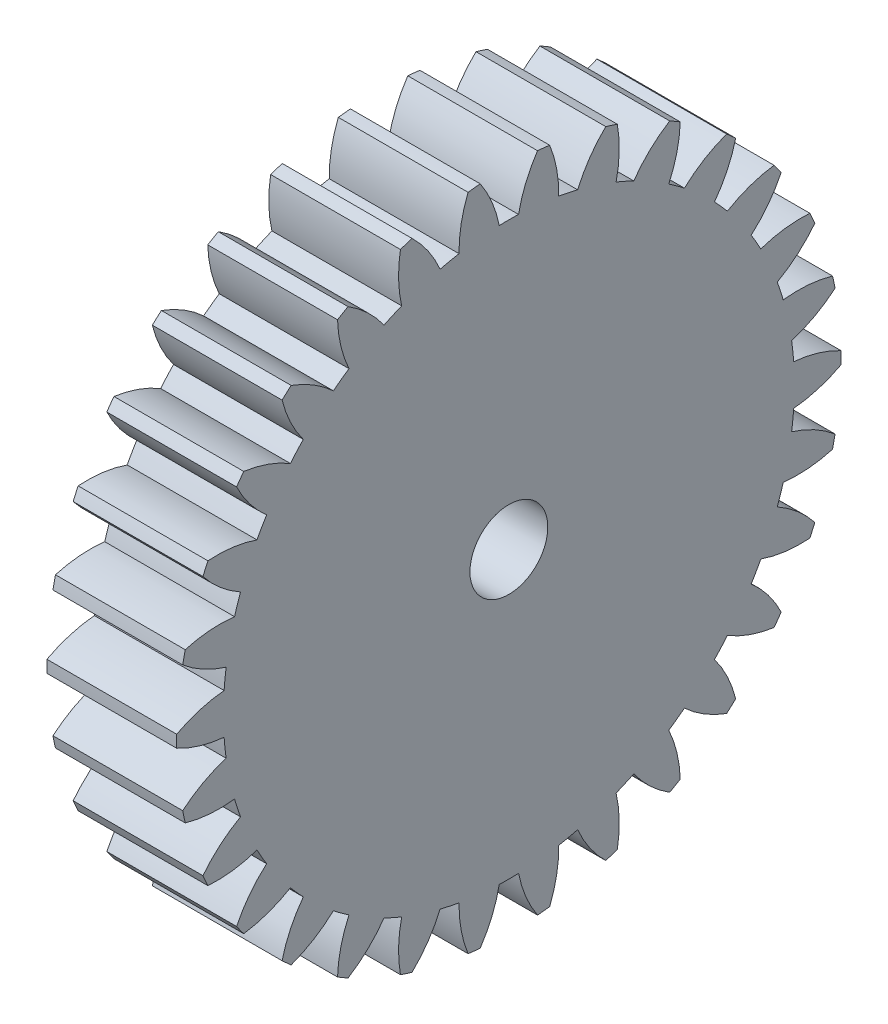
from build123d import *

# Parameters (mm, degrees)
BASPROSKE_W     = 5
BASPROSKE_H     = 12.8
TOOTHCUT_DEPTH  = 19.779776356
TEETHCUTS_COUNT = 30
TEETHCUTS_ANGLE = 348
BORSKE_R        = 1.5
BORE_DEPTH      = 50.0000508


with BuildPart() as part:
    # BasProSke → Base-Revolve (revolve)
    with BuildSketch(Plane(origin=(0, 0, 0), x_dir=(1, 0, 0), z_dir=(0, 1, 0)), mode=Mode.PRIVATE) as base_revolve_sk:
        with Locations((2.5, 6.4)):
            Rectangle(BASPROSKE_W, BASPROSKE_H)
    revolve(base_revolve_sk.sketch.rotate(Axis((-10, 0, 0), (1, 0, 0)), 180), axis=Axis((-10, 0, 0), (1, 0, 0)))

    # TooCutSke → ToothCut (cut, through all)
    with BuildSketch(Plane(origin=(0, 0, 0), x_dir=(0, 0, -1), z_dir=(1, 0, 0))):
        with BuildLine():
            ThreePointArc((0.37243947, 10.992692566), (0, 10.999), (-0.37243947, 10.992692566))
            ThreePointArc((-0.37243947, 10.992692566), (-0.655704499, 11.922595954), (-1.120515575, 12.776358245))
            ThreePointArc((-1.120515575, 12.776358245), (0, 12.8254), (1.120515575, 12.776358245))
            ThreePointArc((1.120515575, 12.776358245), (0.655704499, 11.922595954), (0.37243947, 10.992692566))
        make_face()
    toothcut = extrude(amount=TOOTHCUT_DEPTH, mode=Mode.SUBTRACT)

    # TeethCuts: ToothCut ×30 about axis
    teethcuts_axis = Axis((-10, 0, 0), (1, 0, 0))
    for i in range(1, TEETHCUTS_COUNT):
        add(toothcut.rotate(teethcuts_axis, i * TEETHCUTS_ANGLE / (TEETHCUTS_COUNT - 1)), mode=Mode.SUBTRACT)

    # BorSke → Bore (cut, symmetric)
    with BuildSketch(Plane(origin=(0, 0, 0), x_dir=(0, 0, -1), z_dir=(1, 0, 0))):
        with Locations(Location((0, 0, 0), (0, 0, 180))):
            Circle(BORSKE_R)
    extrude(amount=BORE_DEPTH, both=True, mode=Mode.SUBTRACT)


solid = part.part
